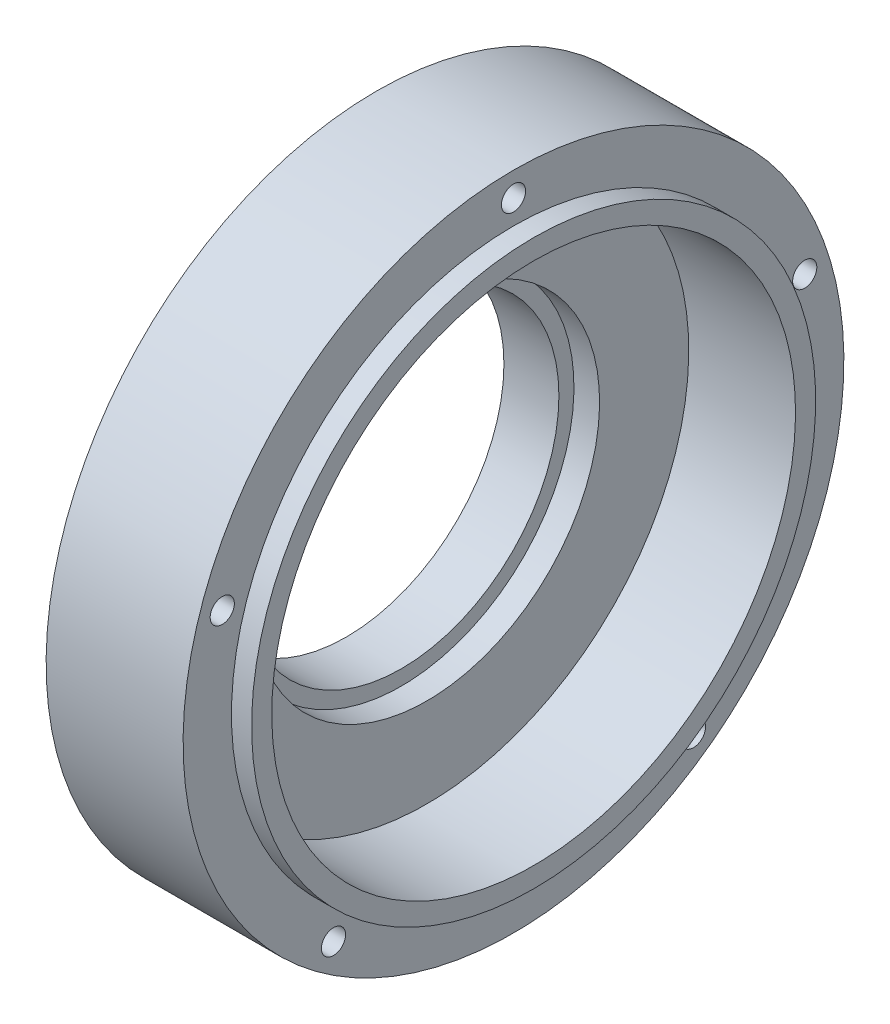
from build123d import *

# Parameters (mm, degrees)
FILLET3_R          = 5
SKETCH2_R          = 6
CUT_EXTRUDE1_DEPTH = 68
CIRPATTERN1_COUNT  = 5


with BuildPart() as part:
    # Sketch1 → Revolve1 (revolve)
    with BuildSketch(Plane.XY):
        Polygon((0, 130), (0, 85.73), (-12.7, 85.73), (-12.7, 78.25), (-40, 78.25), (-40, 88.25), (-25, 88.25), (-25, 164), (43, 164), (43, 140), (53, 140), (53, 130), align=None)
    revolve(axis=Axis((100.288511214, 0, 0), (-1, 0, 0)))

    # Fillet3
    fillet3_edges = [part.edges().sort_by_distance(p)[0] for p in [
        (-25, -88.25, 0),
    ]]
    fillet(fillet3_edges, radius=FILLET3_R)

    # Sketch2 → Cut-Extrude1 (cut)
    with BuildSketch(Plane(origin=(43, 0, 0), x_dir=(0, 0, -1), z_dir=(1, 0, 0))):
        with Locations((0, 152)):
            Circle(SKETCH2_R)
    cut_extrude1 = extrude(amount=-CUT_EXTRUDE1_DEPTH, mode=Mode.SUBTRACT)

    # CirPattern1: Cut-Extrude1 ×5 about axis
    cirpattern1_axis = Axis((0, 0, 0), (1, 0, 0))
    for i in range(1, CIRPATTERN1_COUNT):
        add(cut_extrude1.rotate(cirpattern1_axis, i * 360 / CIRPATTERN1_COUNT), mode=Mode.SUBTRACT)


solid = part.part
